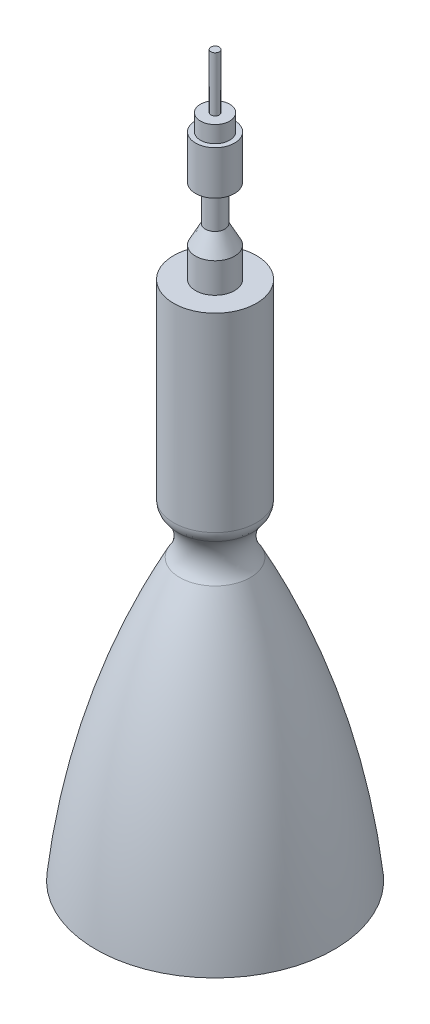
from build123d import *

# Parameters (mm, degrees)
FILLET1_R = 10


with BuildPart() as part:
    # Sketch1 → Revolve1 (revolve)
    with BuildSketch(Plane.XY):
        with BuildLine():
            Line((0, 0), (76, 0))
            ThreePointArc((76, 0), (57.779229612, 91.871941274), (22.501351501, 178.635536076))
            ThreePointArc((22.501351501, 178.635536076), (18.690152094, 193.361033944), (26.407726548, 206.468458288))
            Line((26.407726548, 206.468458288), (26.407726548, 332))
            Line((26.407726548, 332), (0, 332))
            Line((0, 332), (0, 0))
        make_face()
    revolve(axis=Axis((0, 0, 0), (0, 1, 0)))

    # Fillet1
    fillet1_edges = [part.edges().sort_by_distance(p)[0] for p in [
        (-26.407726548, 206.468458288, 0),
    ]]
    fillet(fillet1_edges, radius=FILLET1_R)

    # Sketch2 → Revolve2 (revolve)
    with BuildSketch(Plane.XY):
        Polygon((0, 332), (0, 459), (2.664793977, 459), (2.664793977, 424.102348648), (9.322424203, 424.102348648), (9.322424203, 413.501049111), (12.429898937, 413.501049111), (12.429898937, 385.623557734), (6.214949468, 385.623557734), (6.214949468, 362.850395765), (12.429898937, 351.071174056), (12.429898937, 332), align=None)
    revolve(axis=Axis((0, 332, 0), (0, 1, 0)))


solid = part.part
